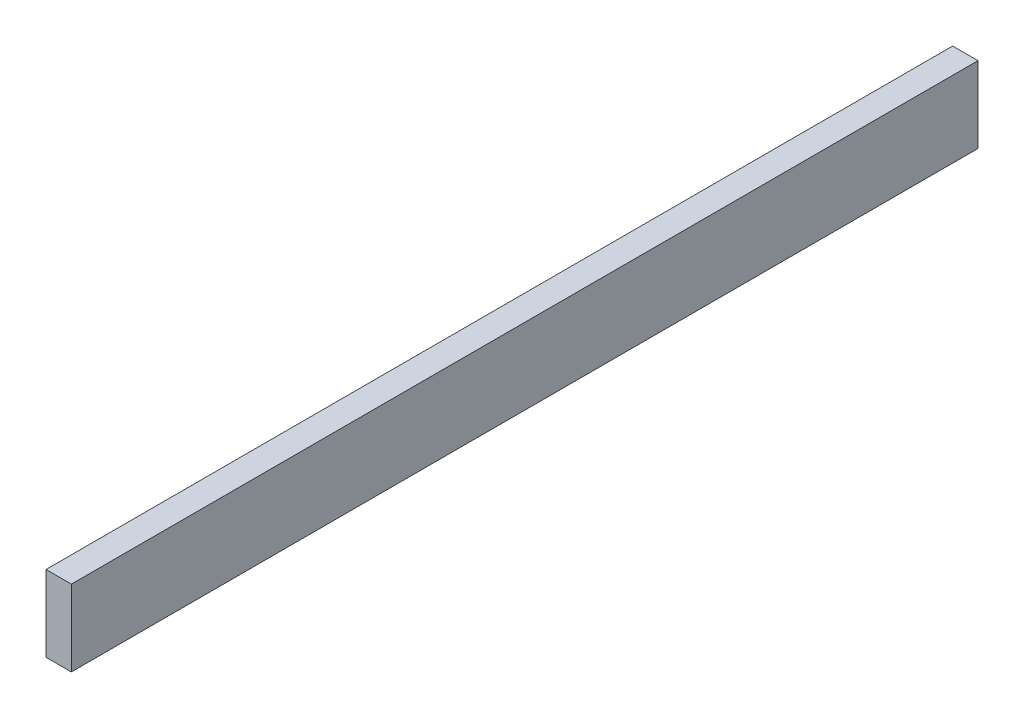
from build123d import *

# Parameters (mm, degrees)
SKETCH1_W           = 20
SKETCH1_H           = 715
BOSS_EXTRUDE1_DEPTH = 60


with BuildPart() as part:
    # Sketch1 → Boss-Extrude1 (new body)
    with BuildSketch(Plane(origin=(0, 0, 0), x_dir=(1, 0, 0), z_dir=(0, 1, 0))):
        Rectangle(SKETCH1_W, SKETCH1_H)
    extrude(amount=BOSS_EXTRUDE1_DEPTH)


solid = part.part
